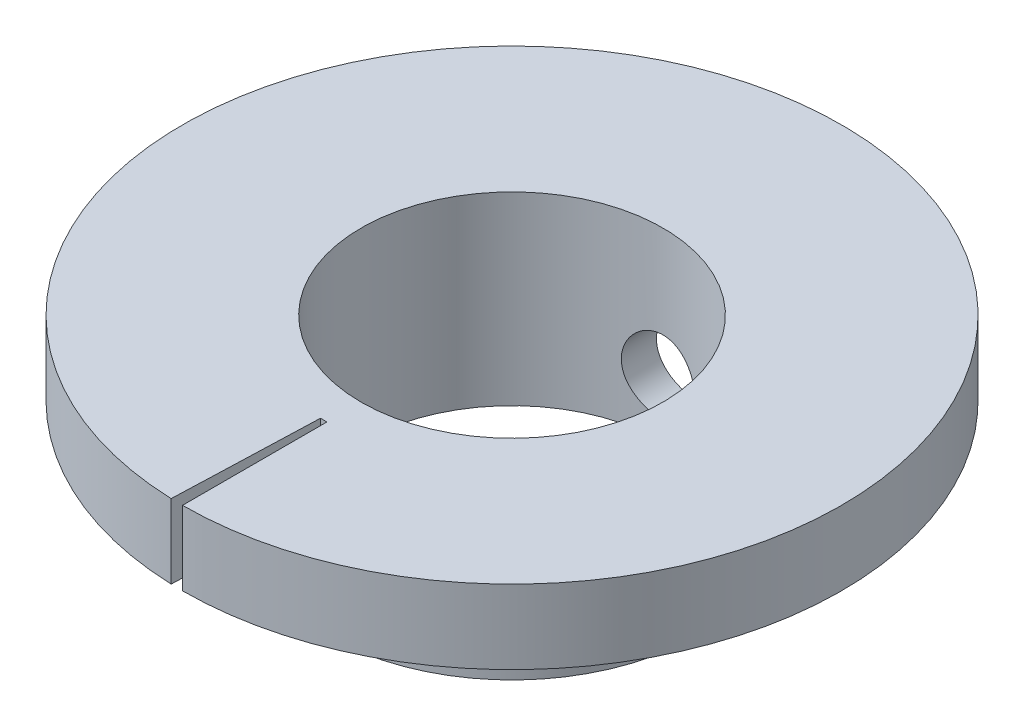
from build123d import *

# Parameters (mm, degrees)
SKETCH1_R           = 8.9
SKETCH1_R_2         = 4
BOSS_EXTRUDE1_DEPTH = 2
CUT_EXTRUDE1_DEPTH  = 2
SKETCH3_R           = 5
SKETCH3_R_2         = 4
BOSS_EXTRUDE2_DEPTH = 5
SKETCH4_R           = 4.075
CUT_EXTRUDE2_DEPTH  = 15
SKETCH6_R           = 1
CUT_EXTRUDE3_DEPTH  = 15


with BuildPart() as part:
    # Sketch1 → Boss-Extrude1 (new body)
    with BuildSketch(Plane(origin=(0, 0, 0), x_dir=(1, 0, 0), z_dir=(0, 1, 0))):
        Circle(SKETCH1_R)
        Circle(SKETCH1_R_2, mode=Mode.SUBTRACT)
    extrude(amount=BOSS_EXTRUDE1_DEPTH)

    # Sketch2 → Cut-Extrude1 (cut)
    with BuildSketch(Plane(origin=(0, 2, 0), x_dir=(1, 0, 0), z_dir=(0, 1, 0))):
        Polygon((0, 0), (0, -10.52604124), (-0.355401251, -10.177360244), align=None)
    extrude(amount=-CUT_EXTRUDE1_DEPTH, mode=Mode.SUBTRACT)

    # Sketch3 → Boss-Extrude2 (add)
    with BuildSketch(Plane(origin=(0, 2, 0), x_dir=(1, 0, 0), z_dir=(0, 1, 0))):
        Circle(SKETCH3_R)
        Circle(SKETCH3_R_2, mode=Mode.SUBTRACT)
    extrude(amount=-BOSS_EXTRUDE2_DEPTH)

    # Sketch4 → Cut-Extrude2 (cut)
    with BuildSketch(Plane(origin=(0, 2, 0), x_dir=(1, 0, 0), z_dir=(0, 1, 0))):
        Circle(SKETCH4_R)
    extrude(amount=-CUT_EXTRUDE2_DEPTH, mode=Mode.SUBTRACT)

    # Sketch6 → Cut-Extrude3 (cut)
    with BuildSketch(Plane.XY):
        with Locations((0, -1.5)):
            Circle(SKETCH6_R)
    extrude(amount=-CUT_EXTRUDE3_DEPTH, mode=Mode.SUBTRACT)


solid = part.part
